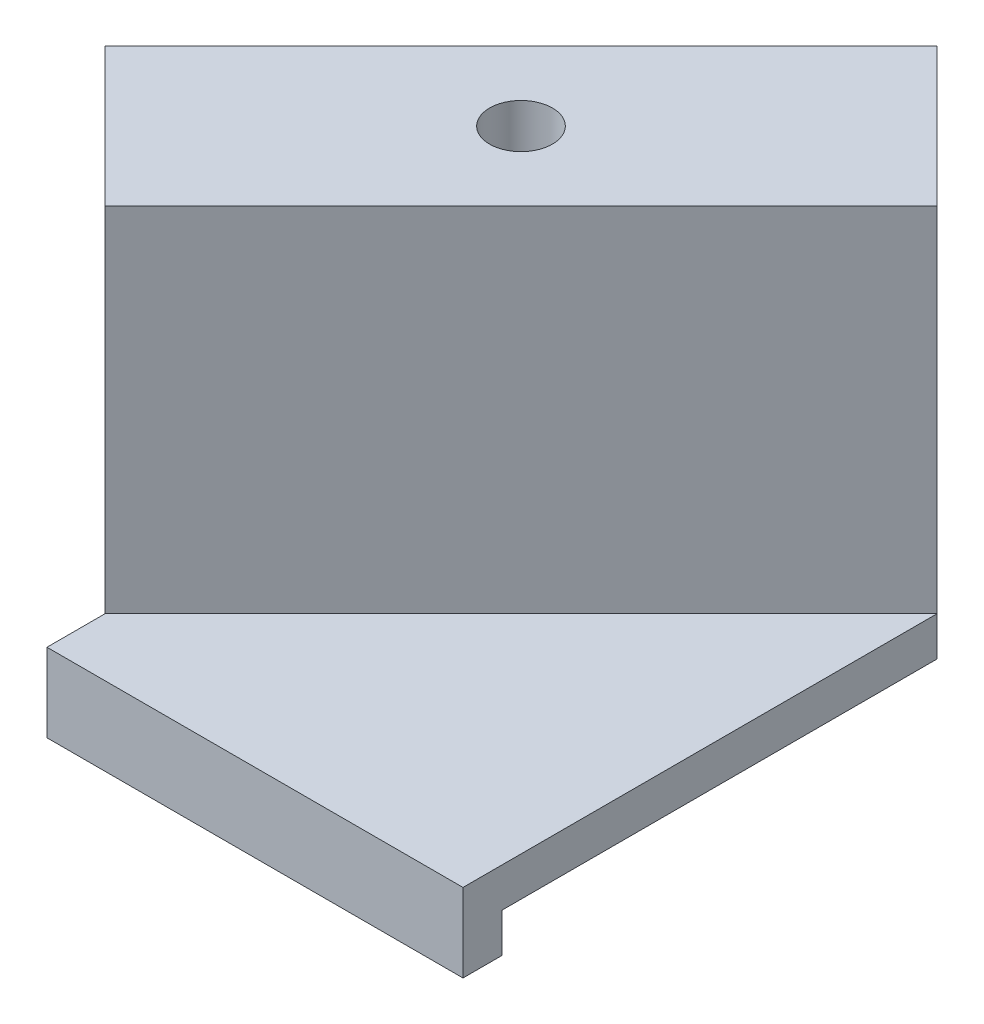
from build123d import *

# Parameters (mm, degrees)
SKETCH1_R                = 1.6
BOSS_EXTRUDE1_DEPTH      = 20
BOSS_EXTRUDE2_DEPTH      = 2
BOSS_EXTRUDE3_DEPTH      = 2
BOSS_EXTRUDE3_DEPTH_BACK = 2
SKETCH1_4_W              = 21.213203436
SKETCH1_4_H              = 2


with BuildPart() as part:
    # Sketch1 → Boss-Extrude1 (new body)
    with BuildSketch(Plane(origin=(0, 0, 0), x_dir=(1, 0, 0), z_dir=(0, 1, 0))):
        Polygon((-14.142135624, -7.071067812), (-7.071067812, -14.142135624), (14.142135624, 7.071067812), (7.071067812, 14.142135624), align=None)
        Circle(SKETCH1_R, mode=Mode.SUBTRACT)
    extrude(amount=BOSS_EXTRUDE1_DEPTH)

    # Sketch1_3 → Boss-Extrude2 (add)
    with BuildSketch(Plane(origin=(0, 0, 0), x_dir=(1, 0, 0), z_dir=(0, 1, 0))):
        Polygon((14.142135624, 7.071067812), (-7.071067812, -14.142135624), (-7.071067812, -15.1), (14.142135624, -15.1), align=None)
    extrude(amount=BOSS_EXTRUDE2_DEPTH)

    # Sketch1_4 → Boss-Extrude3 (add, two sides: drawn at the far end of the back side and taken through both)
    with BuildSketch(Plane(origin=(0, 0, 0), x_dir=(1, 0, 0), z_dir=(0, 1, 0)).offset(-BOSS_EXTRUDE3_DEPTH_BACK)):
        with Locations((3.535533906, -16.1)):
            Rectangle(SKETCH1_4_W, SKETCH1_4_H)
    extrude(amount=BOSS_EXTRUDE3_DEPTH + BOSS_EXTRUDE3_DEPTH_BACK)


solid = part.part
